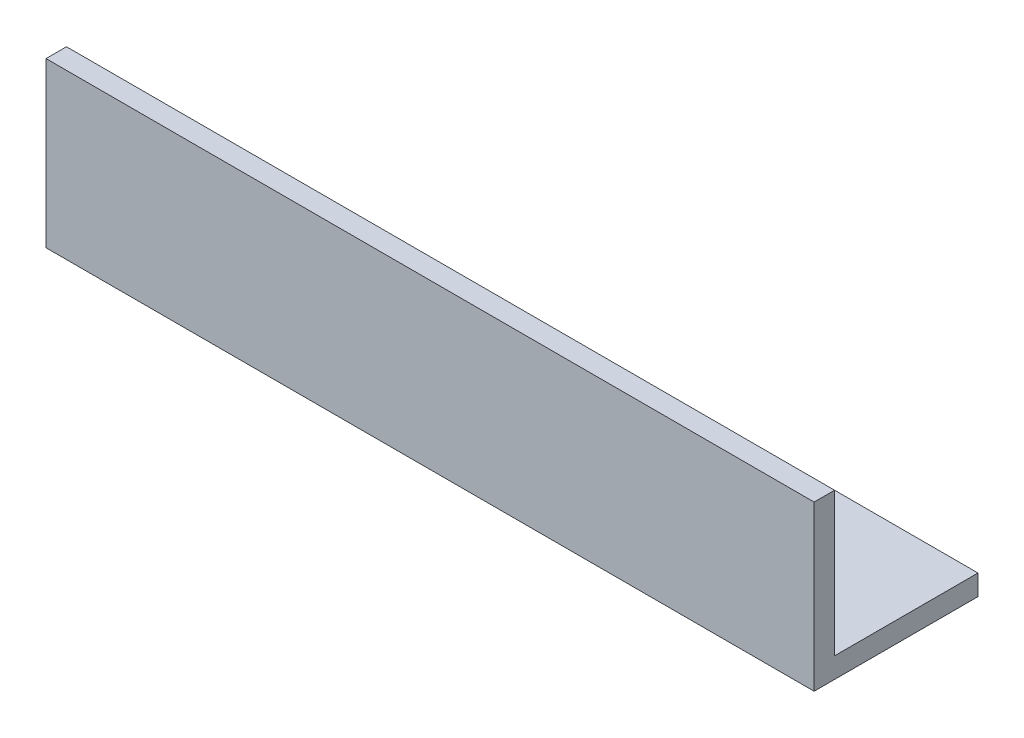
from build123d import *

# Parameters (mm, degrees)
EXTRUDE_1_DEPTH     = 150
SKETCH_2_R          = 5
CUT_EXTRUDE_1_DEPTH = 33


with BuildPart() as part:
    # Эскиз1 → Вытянуть-Тонкостенный1 (new body)
    with BuildSketch(Plane(origin=(0, 0, 0), x_dir=(0, 0, -1), z_dir=(1, 0, 0))):
        Polygon((32, 0), (0, 0), (0, 32), (4, 32), (4, 4), (32, 4), align=None)
    extrude(amount=EXTRUDE_1_DEPTH)

    # Эскиз2 → Вырез-Вытянуть1 (cut, through all)
    with BuildSketch(Plane.XZ):
        with Locations((130, -13)):
            Circle(SKETCH_2_R)
        with Locations((100, -13)):
            Circle(SKETCH_2_R)
        with Locations((50, -13)):
            Circle(SKETCH_2_R)
        with Locations((20, -13)):
            Circle(SKETCH_2_R)
    extrude(amount=-CUT_EXTRUDE_1_DEPTH, mode=Mode.SUBTRACT)


solid = part.part
